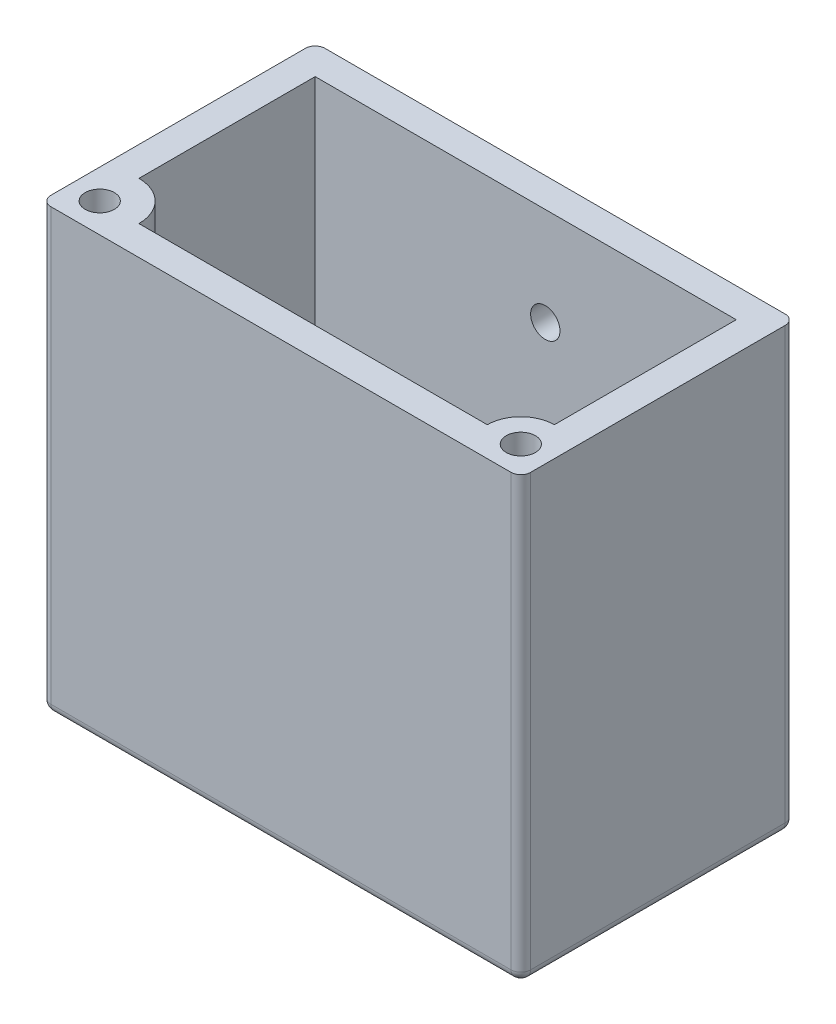
from build123d import *

# Parameters (mm, degrees)
SKETCH1_W           = 49
SKETCH1_H           = 28
BOSS_EXTRUDE1_DEPTH = 45
SKETCH2_W           = 43
SKETCH2_H           = 22
CUT_EXTRUDE1_DEPTH  = 43
SKETCH3_W           = 29
SKETCH3_H           = 8
CUT_EXTRUDE2_DEPTH  = 3
SKETCH4_R           = 1.5
CUT_EXTRUDE3_DEPTH  = 3
BOSS_EXTRUDE2_DEPTH = 45
SKETCH6_R           = 1.49
CUT_EXTRUDE4_DEPTH  = 45
BOSS_EXTRUDE3_DEPTH = 45
SKETCH8_R           = 1.49
CUT_EXTRUDE5_DEPTH  = 45
FILLET2_R           = 1


with BuildPart() as part:
    # Sketch1 → Boss-Extrude1 (new body)
    with BuildSketch(Plane(origin=(0, 0, 0), x_dir=(1, 0, 0), z_dir=(0, 1, 0))):
        with Locations((-4.986725664, 3.221238938)):
            Rectangle(SKETCH1_W, SKETCH1_H)
    extrude(amount=BOSS_EXTRUDE1_DEPTH)

    # Sketch2 → Cut-Extrude1 (cut)
    with BuildSketch(Plane(origin=(0, 45, 0), x_dir=(1, 0, 0), z_dir=(0, 1, 0))):
        with Locations((-4.986725664, 3.221238938)):
            Rectangle(SKETCH2_W, SKETCH2_H)
    extrude(amount=-CUT_EXTRUDE1_DEPTH, mode=Mode.SUBTRACT)

    # Sketch3 → Cut-Extrude2 (cut)
    with BuildSketch(Plane(origin=(0, 2, 0), x_dir=(1, 0, 0), z_dir=(0, 1, 0))):
        with Locations((-4.986725664, 7.221238938)):
            Rectangle(SKETCH3_W, SKETCH3_H)
    extrude(amount=-CUT_EXTRUDE2_DEPTH, mode=Mode.SUBTRACT)

    # Sketch4 → Cut-Extrude3 (cut)
    with BuildSketch(Plane.XY.offset(-14.221238938)):
        with Locations((-2.986725664, 35)):
            Circle(SKETCH4_R)
    extrude(amount=-CUT_EXTRUDE3_DEPTH, mode=Mode.SUBTRACT)

    # Sketch5 → Boss-Extrude2 (add)
    with BuildSketch(Plane.XZ):
        with BuildLine():
            Line((14.867523025, 10.778761062), (19.513274336, 10.778761062))
            Line((19.513274336, 10.778761062), (19.513274336, 6.133009751))
            ThreePointArc((19.513274336, 6.133009751), (14.093718863, 5.359205589), (14.867523025, 10.778761062))
        make_face()
    extrude(amount=-BOSS_EXTRUDE2_DEPTH)

    # Sketch6 → Cut-Extrude4 (cut)
    with BuildSketch(Plane.XZ):
        with Locations((16.513274336, 7.778761062)):
            Circle(SKETCH6_R)
    extrude(amount=-CUT_EXTRUDE4_DEPTH, mode=Mode.SUBTRACT)

    # Sketch7 → Boss-Extrude3 (add)
    with BuildSketch(Plane.XZ):
        with BuildLine():
            Line((-29.486725664, 5.133009751), (-29.486725664, 10.778761062))
            Line((-29.486725664, 10.778761062), (-23.840974353, 10.778761062))
            ThreePointArc((-23.840974353, 10.778761062), (-23.658298539, 4.950333937), (-29.486725664, 5.133009751))
        make_face()
    extrude(amount=-BOSS_EXTRUDE3_DEPTH)

    # Sketch8 → Cut-Extrude5 (cut)
    with BuildSketch(Plane.XZ):
        with Locations((-26.486725664, 7.778761062)):
            Circle(SKETCH8_R)
    extrude(amount=-CUT_EXTRUDE5_DEPTH, mode=Mode.SUBTRACT)

    # Fillet2
    fillet2_edges = [part.edges().sort_by_distance(p)[0] for p in [
        (-4.986725664, 0, -17.221238938),
        (19.513274336, 0, -3.221238938),
        (-4.986725664, 0, 10.778761062),
        (-29.486725664, 0, -3.221238938),
        (-29.486725664, 22.5, -17.221238938),
        (19.513274336, 22.5, -17.221238938),
        (19.513274336, 22.5, 10.778761062),
        (-29.486725664, 22.5, 10.778761062),
    ]]
    fillet(fillet2_edges, radius=FILLET2_R)


solid = part.part
